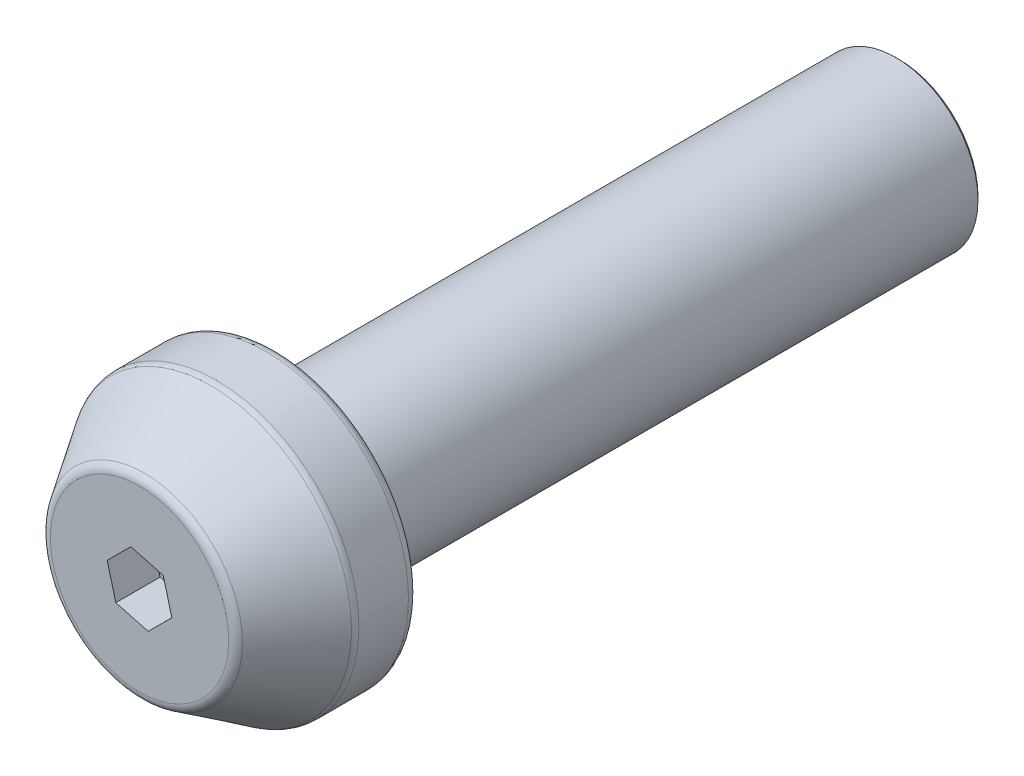
from build123d import *

# Parameters (mm, degrees)
SKETCH1_R             = 3.9
BOSS_EXTRUDE1_DEPTH   = 29.5
SKETCH2_R             = 6.75
BOSS_EXTRUDE2_DEPTH   = 3
SKETCH3_R             = 4.5
FILLET1_R             = 0.5
CUT_EXTRUDE1_DEPTH    = 2.1
M6_TAPPED_HOLE1_D     = 5
M6_TAPPED_HOLE1_DEPTH = 15
M6_TAPPED_HOLE1_TIP   = 1.502151548
CHAMFER1_SIZE         = 0.15


with BuildPart() as part:
    # Sketch1 → Boss-Extrude1 (new body)
    with BuildSketch(Plane.XY):
        Circle(SKETCH1_R)
    extrude(amount=BOSS_EXTRUDE1_DEPTH)

    # Sketch2 → Boss-Extrude2 (add)
    with BuildSketch(Plane.XY.offset(29.5)):
        Circle(SKETCH2_R)
    extrude(amount=BOSS_EXTRUDE2_DEPTH)

    # Sketch3 → section 1 of loft1
    with BuildSketch(Plane.XY.offset(36), mode=Mode.PRIVATE) as loft1_s1:
        Circle(SKETCH3_R)
    # loft up to a face of the part (loft1)
    loft([Face(Wire([part.edges().sort_by_distance((-4.620692965, 4.920538235, 32.5))[0]])), loft1_s1.sketch])

    # Fillet1
    fillet1_edges = [part.edges().sort_by_distance(p)[0] for p in [
        (-6.75, 0, 29.5),
        (-6.75, 0, 32.5),
        (-4.5, 0, 36),
    ]]
    fillet(fillet1_edges, radius=FILLET1_R)

    # Sketch6 → Cut-Extrude1 (cut)
    with BuildSketch(Plane.XY.offset(36)):
        Polygon((1.533242561, -0.412311271), (1.123693315, 1.121671372), (-0.409549246, 1.533982643), (-1.533242561, 0.412311271), (-1.123693315, -1.121671372), (0.409549246, -1.533982643), align=None)
    extrude(amount=-CUT_EXTRUDE1_DEPTH, mode=Mode.SUBTRACT)

    # M6 Tapped Hole1
    with Locations(Plane(origin=(0, 0, 0), x_dir=(-1, 0, 0), z_dir=(0, 0, -1))):
        with Locations((0, 0)):
            Hole(M6_TAPPED_HOLE1_D / 2, depth=M6_TAPPED_HOLE1_DEPTH)
            with Locations((0, 0, -(M6_TAPPED_HOLE1_DEPTH + M6_TAPPED_HOLE1_TIP / 2))):  # 118° drill point
                Cone(0, M6_TAPPED_HOLE1_D / 2, M6_TAPPED_HOLE1_TIP, mode=Mode.SUBTRACT)

    # Chamfer1
    chamfer1_edges = [part.edges().sort_by_distance(p)[0] for p in [
        (-3.9, 0, 0),
    ]]
    chamfer(chamfer1_edges, length=CHAMFER1_SIZE)


solid = part.part
